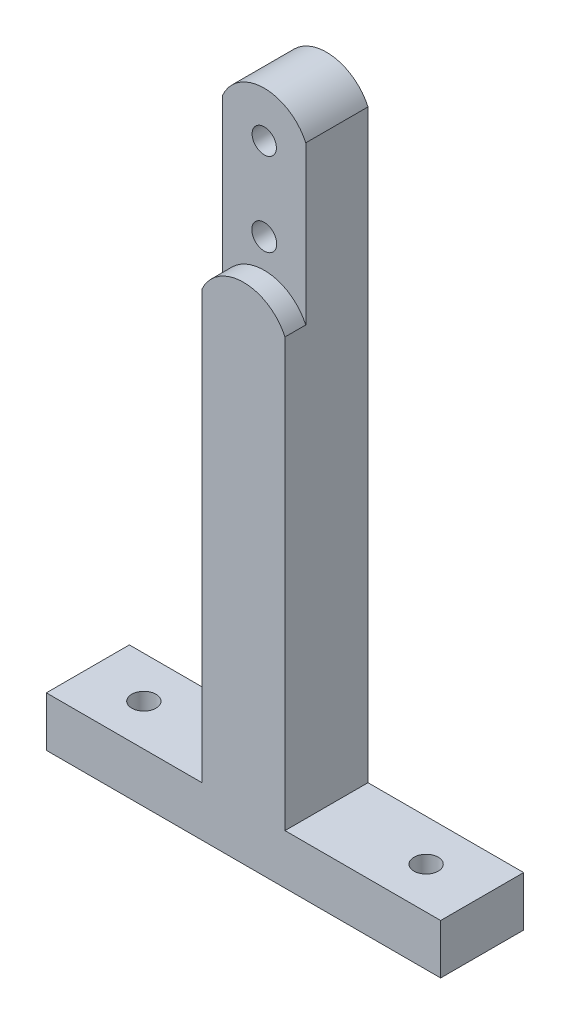
from build123d import *

# Parameters (mm, degrees)
SKETCH1_R           = 3
SKETCH1_R_2         = 2.925
BOSS_EXTRUDE1_DEPTH = 20
CUT_EXTRUDE1_DEPTH  = 5
SKETCH3_R           = 2.925
CUT_EXTRUDE2_DEPTH  = 13


with BuildPart() as part:
    # Sketch1 → Boss-Extrude1 (new body)
    with BuildSketch(Plane.XY):
        with BuildLine():
            Line((-10, -128.247424305), (-10, -269.247424305))
            Line((-10, -269.247424305), (-47.5, -269.247424305))
            Line((-47.5, -269.247424305), (-47.5, -281.247424305))
            Line((-47.5, -281.247424305), (47.5, -281.247424305))
            Line((47.5, -281.247424305), (47.5, -269.247424305))
            Line((47.5, -269.247424305), (10, -269.247424305))
            Line((10, -269.247424305), (10, -128.247424305))
            ThreePointArc((10, -128.247424305), (0, -121.83), (-10, -128.247424305))
        make_face()
        with Locations((0, -152.83)):
            Circle(SKETCH1_R, mode=Mode.SUBTRACT)
        with Locations((0, -132.83)):
            Circle(SKETCH1_R_2, mode=Mode.SUBTRACT)
    extrude(amount=BOSS_EXTRUDE1_DEPTH)

    # Sketch2 → Cut-Extrude1 (cut)
    with BuildSketch(Plane.XY.offset(20)):
        with BuildLine():
            Line((-10, -128.247424305), (-10, -166.247424305))
            ThreePointArc((-10, -166.247424305), (0, -159.83), (10, -166.247424305))
            Line((10, -166.247424305), (10, -128.247424305))
            ThreePointArc((10, -128.247424305), (0, -121.83), (-10, -128.247424305))
        make_face()
    extrude(amount=-CUT_EXTRUDE1_DEPTH, mode=Mode.SUBTRACT)

    # Sketch3 → Cut-Extrude2 (cut, through all)
    with BuildSketch(Plane(origin=(0, -269.247424305, 0), x_dir=(1, 0, 0), z_dir=(0, 1, 0))):
        with Locations((-34, -10)):
            Circle(SKETCH3_R)
        with Locations((34, -10)):
            Circle(SKETCH3_R)
    extrude(amount=-CUT_EXTRUDE2_DEPTH, mode=Mode.SUBTRACT)


solid = part.part
